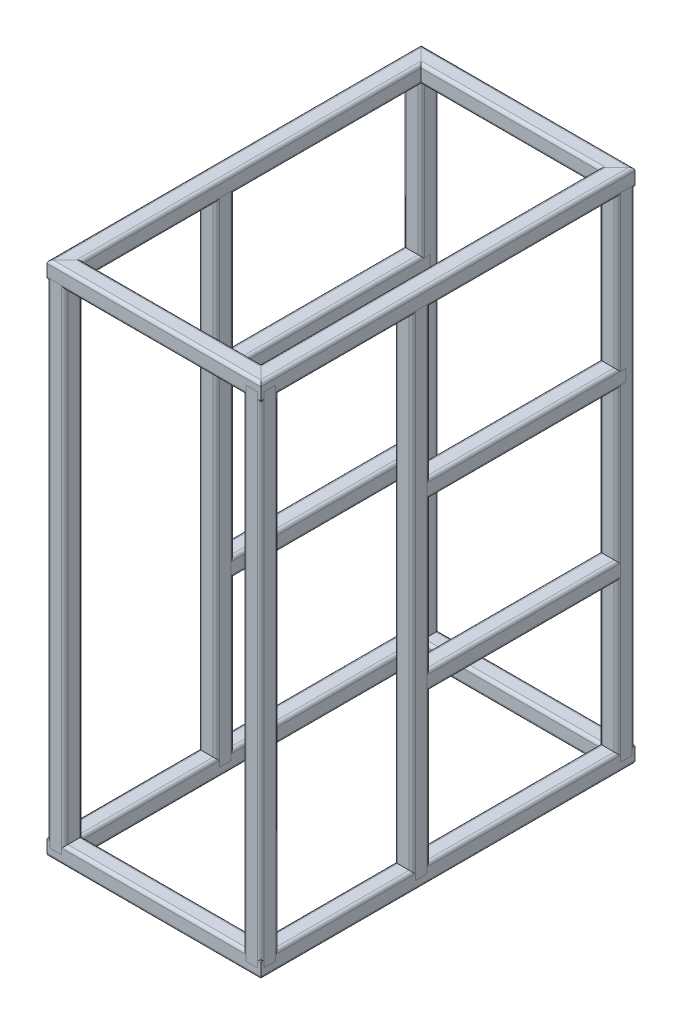
from build123d import *

# Parameters (mm, degrees)
F_30_X_30_X_2_6_1_DEPTH      = 352.213203436
F_30_X_30_X_2_6_1_DEPTH_BACK = 22.213203436
F_30_X_30_X_2_6_1_2_DEPTH    = 644.426406871
F_30_X_30_X_2_6_1_3_DEPTH    = 374.426406871
F_30_X_30_X_2_6_1_4_DEPTH    = 644.426406871
F_30_X_30_X_2_6_2_DEPTH      = 840
F_30_X_30_X_2_6_2_2_DEPTH    = 840
F_30_X_30_X_2_6_2_3_DEPTH    = 840
F_30_X_30_X_2_6_2_4_DEPTH    = 840
F_30_X_30_X_2_6_4_DEPTH      = 352.213203436
F_30_X_30_X_2_6_4_DEPTH_BACK = 22.213203436
F_30_X_30_X_2_6_4_2_DEPTH    = 644.426406871
F_30_X_30_X_2_6_4_3_DEPTH    = 374.426406871
F_30_X_30_X_2_6_4_4_DEPTH    = 644.426406871
F_30_X_30_X_2_6_5_DEPTH      = 840
F_30_X_30_X_2_6_5_2_DEPTH    = 840
F_30_X_30_X_2_6_6_DEPTH      = 345
F_30_X_30_X_2_6_6_2_DEPTH    = 345
F_30_X_30_X_2_6_6_3_DEPTH    = 345
F_30_X_30_X_2_6_6_4_DEPTH    = 345


with BuildPart() as part:
    # Sketch1 → 方形管 30 X 30 X 2.6(1) (new, two sides)
    with BuildSketch(Plane(origin=(-165, -420, 0), x_dir=(0, 1, 0), z_dir=(1, 0, 0))) as f_30_x_30_x_2_6_1_sk:
        with BuildLine():
            Line((-9.8, -15), (9.8, -15))
            ThreePointArc((9.8, -15), (13.476955262, -13.476955262), (15, -9.8))
            Line((15, -9.8), (15, 9.8))
            ThreePointArc((15, 9.8), (13.476955262, 13.476955262), (9.8, 15))
            Line((9.8, 15), (-9.8, 15))
            ThreePointArc((-9.8, 15), (-13.476955262, 13.476955262), (-15, 9.8))
            Line((-15, 9.8), (-15, -9.8))
            ThreePointArc((-15, -9.8), (-13.476955262, -13.476955262), (-9.8, -15))
        make_face()
        with BuildLine():
            Line((-9.8, -12.4), (9.8, -12.4))
            ThreePointArc((9.8, -12.4), (11.638477631, -11.638477631), (12.4, -9.8))
            Line((12.4, -9.8), (12.4, 9.8))
            ThreePointArc((12.4, 9.8), (11.638477631, 11.638477631), (9.8, 12.4))
            Line((9.8, 12.4), (-9.8, 12.4))
            ThreePointArc((-9.8, 12.4), (-11.638477631, 11.638477631), (-12.4, 9.8))
            Line((-12.4, 9.8), (-12.4, -9.8))
            ThreePointArc((-12.4, -9.8), (-11.638477631, -11.638477631), (-9.8, -12.4))
        make_face(mode=Mode.SUBTRACT)
    extrude(amount=F_30_X_30_X_2_6_1_DEPTH)
    extrude(f_30_x_30_x_2_6_1_sk.sketch, amount=-F_30_X_30_X_2_6_1_DEPTH_BACK)

    # 方形管 30 X 30 X 2.6(1) mitre 1
    split(bisect_by=Plane(origin=(-165, -420, 0), x_dir=(0, 1, 0), z_dir=(0.707106781, 0, 0.707106781)), keep=Keep.TOP)

    # 方形管 30 X 30 X 2.6(1) mitre 2
    split(bisect_by=Plane(origin=(165, -420, 0), x_dir=(0, -1, 0), z_dir=(-0.707106781, 0, 0.707106781)), keep=Keep.TOP)


with BuildPart() as body_2:
    # Sketch1 on segment 2 (carried to segment 2) → 30 X 30 X 2.6_1 2 (new body)
    with BuildSketch(Plane(origin=(165, -420, 22.213203436), x_dir=(0, 1, 0), z_dir=(0, 0, -1))):
        with BuildLine():
            Line((-9.8, -15), (9.8, -15))
            ThreePointArc((9.8, -15), (13.476955262, -13.476955262), (15, -9.8))
            Line((15, -9.8), (15, 9.8))
            ThreePointArc((15, 9.8), (13.476955262, 13.476955262), (9.8, 15))
            Line((9.8, 15), (-9.8, 15))
            ThreePointArc((-9.8, 15), (-13.476955262, 13.476955262), (-15, 9.8))
            Line((-15, 9.8), (-15, -9.8))
            ThreePointArc((-15, -9.8), (-13.476955262, -13.476955262), (-9.8, -15))
        make_face()
        with BuildLine():
            Line((-9.8, -12.4), (9.8, -12.4))
            ThreePointArc((9.8, -12.4), (11.638477631, -11.638477631), (12.4, -9.8))
            Line((12.4, -9.8), (12.4, 9.8))
            ThreePointArc((12.4, 9.8), (11.638477631, 11.638477631), (9.8, 12.4))
            Line((9.8, 12.4), (-9.8, 12.4))
            ThreePointArc((-9.8, 12.4), (-11.638477631, 11.638477631), (-12.4, 9.8))
            Line((-12.4, 9.8), (-12.4, -9.8))
            ThreePointArc((-12.4, -9.8), (-11.638477631, -11.638477631), (-9.8, -12.4))
        make_face(mode=Mode.SUBTRACT)
    extrude(amount=F_30_X_30_X_2_6_1_2_DEPTH)

    # 30 X 30 X 2.6_1 2 mitre 1
    split(bisect_by=Plane(origin=(165, -420, 0), x_dir=(0, 1, 0), z_dir=(0.707106781, 0, -0.707106781)), keep=Keep.TOP)

    # 30 X 30 X 2.6_1 2 mitre 2
    split(bisect_by=Plane(origin=(165, -420, -600), x_dir=(0, 1, 0), z_dir=(0.707106781, 0, 0.707106781)), keep=Keep.TOP)


with BuildPart() as body_3:
    # Sketch1 on segment 3 (carried to segment 3) → 30 X 30 X 2.6_1 3 (new body)
    with BuildSketch(Plane(origin=(187.213203436, -420, -600), x_dir=(0, 1, 0), z_dir=(-1, 0, 0))):
        with BuildLine():
            Line((-9.8, -15), (9.8, -15))
            ThreePointArc((9.8, -15), (13.476955262, -13.476955262), (15, -9.8))
            Line((15, -9.8), (15, 9.8))
            ThreePointArc((15, 9.8), (13.476955262, 13.476955262), (9.8, 15))
            Line((9.8, 15), (-9.8, 15))
            ThreePointArc((-9.8, 15), (-13.476955262, 13.476955262), (-15, 9.8))
            Line((-15, 9.8), (-15, -9.8))
            ThreePointArc((-15, -9.8), (-13.476955262, -13.476955262), (-9.8, -15))
        make_face()
        with BuildLine():
            Line((-9.8, -12.4), (9.8, -12.4))
            ThreePointArc((9.8, -12.4), (11.638477631, -11.638477631), (12.4, -9.8))
            Line((12.4, -9.8), (12.4, 9.8))
            ThreePointArc((12.4, 9.8), (11.638477631, 11.638477631), (9.8, 12.4))
            Line((9.8, 12.4), (-9.8, 12.4))
            ThreePointArc((-9.8, 12.4), (-11.638477631, 11.638477631), (-12.4, 9.8))
            Line((-12.4, 9.8), (-12.4, -9.8))
            ThreePointArc((-12.4, -9.8), (-11.638477631, -11.638477631), (-9.8, -12.4))
        make_face(mode=Mode.SUBTRACT)
    extrude(amount=F_30_X_30_X_2_6_1_3_DEPTH)

    # 30 X 30 X 2.6_1 3 mitre 1
    split(bisect_by=Plane(origin=(165, -420, -600), x_dir=(0, -1, 0), z_dir=(-0.707106781, 0, -0.707106781)), keep=Keep.TOP)

    # 30 X 30 X 2.6_1 3 mitre 2
    split(bisect_by=Plane(origin=(-165, -420, -600), x_dir=(0, 1, 0), z_dir=(0.707106781, 0, -0.707106781)), keep=Keep.TOP)


with BuildPart() as body_4:
    # Sketch1 on segment 4 (carried to segment 4) → 30 X 30 X 2.6_1 4 (new body)
    with BuildSketch(Plane(origin=(-165, -420, -622.213203436), x_dir=(0, 1, 0), z_dir=(0, 0, 1))):
        with BuildLine():
            Line((-9.8, -15), (9.8, -15))
            ThreePointArc((9.8, -15), (13.476955262, -13.476955262), (15, -9.8))
            Line((15, -9.8), (15, 9.8))
            ThreePointArc((15, 9.8), (13.476955262, 13.476955262), (9.8, 15))
            Line((9.8, 15), (-9.8, 15))
            ThreePointArc((-9.8, 15), (-13.476955262, 13.476955262), (-15, 9.8))
            Line((-15, 9.8), (-15, -9.8))
            ThreePointArc((-15, -9.8), (-13.476955262, -13.476955262), (-9.8, -15))
        make_face()
        with BuildLine():
            Line((-9.8, -12.4), (9.8, -12.4))
            ThreePointArc((9.8, -12.4), (11.638477631, -11.638477631), (12.4, -9.8))
            Line((12.4, -9.8), (12.4, 9.8))
            ThreePointArc((12.4, 9.8), (11.638477631, 11.638477631), (9.8, 12.4))
            Line((9.8, 12.4), (-9.8, 12.4))
            ThreePointArc((-9.8, 12.4), (-11.638477631, 11.638477631), (-12.4, 9.8))
            Line((-12.4, 9.8), (-12.4, -9.8))
            ThreePointArc((-12.4, -9.8), (-11.638477631, -11.638477631), (-9.8, -12.4))
        make_face(mode=Mode.SUBTRACT)
    extrude(amount=F_30_X_30_X_2_6_1_4_DEPTH)

    # 30 X 30 X 2.6_1 4 mitre 1
    split(bisect_by=Plane(origin=(-165, -420, 0), x_dir=(0, -1, 0), z_dir=(-0.707106781, 0, -0.707106781)), keep=Keep.TOP)

    # 30 X 30 X 2.6_1 4 mitre 2
    split(bisect_by=Plane(origin=(-165, -420, -600), x_dir=(0, -1, 0), z_dir=(-0.707106781, 0, 0.707106781)), keep=Keep.TOP)


with BuildPart() as body_5:
    # Sketch11 → 方形管 30 X 30 X 2.6(2) (new body)
    with BuildSketch(Plane(origin=(165, -420, 0), x_dir=(-1, 0, 0), z_dir=(0, 1, 0))):
        with BuildLine():
            Line((-9.8, -15), (9.8, -15))
            ThreePointArc((9.8, -15), (13.476955262, -13.476955262), (15, -9.8))
            Line((15, -9.8), (15, 9.8))
            ThreePointArc((15, 9.8), (13.476955262, 13.476955262), (9.8, 15))
            Line((9.8, 15), (-9.8, 15))
            ThreePointArc((-9.8, 15), (-13.476955262, 13.476955262), (-15, 9.8))
            Line((-15, 9.8), (-15, -9.8))
            ThreePointArc((-15, -9.8), (-13.476955262, -13.476955262), (-9.8, -15))
        make_face()
        with BuildLine():
            Line((-9.8, -12.4), (9.8, -12.4))
            ThreePointArc((9.8, -12.4), (11.638477631, -11.638477631), (12.4, -9.8))
            Line((12.4, -9.8), (12.4, 9.8))
            ThreePointArc((12.4, 9.8), (11.638477631, 11.638477631), (9.8, 12.4))
            Line((9.8, 12.4), (-9.8, 12.4))
            ThreePointArc((-9.8, 12.4), (-11.638477631, 11.638477631), (-12.4, 9.8))
            Line((-12.4, 9.8), (-12.4, -9.8))
            ThreePointArc((-12.4, -9.8), (-11.638477631, -11.638477631), (-9.8, -12.4))
        make_face(mode=Mode.SUBTRACT)
    extrude(amount=F_30_X_30_X_2_6_2_DEPTH)


with BuildPart() as body_6:
    # Sketch11 on segment 2 (carried to segment 2) → 30 X 30 X 2.6_2 2 (new body)
    with BuildSketch(Plane(origin=(-165, -420, 0), x_dir=(-1, 0, 0), z_dir=(0, 1, 0))):
        with BuildLine():
            Line((-9.8, -15), (9.8, -15))
            ThreePointArc((9.8, -15), (13.476955262, -13.476955262), (15, -9.8))
            Line((15, -9.8), (15, 9.8))
            ThreePointArc((15, 9.8), (13.476955262, 13.476955262), (9.8, 15))
            Line((9.8, 15), (-9.8, 15))
            ThreePointArc((-9.8, 15), (-13.476955262, 13.476955262), (-15, 9.8))
            Line((-15, 9.8), (-15, -9.8))
            ThreePointArc((-15, -9.8), (-13.476955262, -13.476955262), (-9.8, -15))
        make_face()
        with BuildLine():
            Line((-9.8, -12.4), (9.8, -12.4))
            ThreePointArc((9.8, -12.4), (11.638477631, -11.638477631), (12.4, -9.8))
            Line((12.4, -9.8), (12.4, 9.8))
            ThreePointArc((12.4, 9.8), (11.638477631, 11.638477631), (9.8, 12.4))
            Line((9.8, 12.4), (-9.8, 12.4))
            ThreePointArc((-9.8, 12.4), (-11.638477631, 11.638477631), (-12.4, 9.8))
            Line((-12.4, 9.8), (-12.4, -9.8))
            ThreePointArc((-12.4, -9.8), (-11.638477631, -11.638477631), (-9.8, -12.4))
        make_face(mode=Mode.SUBTRACT)
    extrude(amount=F_30_X_30_X_2_6_2_2_DEPTH)


with BuildPart() as body_7:
    # Sketch11 on segment 3 (carried to segment 3) → 30 X 30 X 2.6_2 3 (new body)
    with BuildSketch(Plane(origin=(165, -420, -600), x_dir=(-1, 0, 0), z_dir=(0, 1, 0))):
        with BuildLine():
            Line((-9.8, -15), (9.8, -15))
            ThreePointArc((9.8, -15), (13.476955262, -13.476955262), (15, -9.8))
            Line((15, -9.8), (15, 9.8))
            ThreePointArc((15, 9.8), (13.476955262, 13.476955262), (9.8, 15))
            Line((9.8, 15), (-9.8, 15))
            ThreePointArc((-9.8, 15), (-13.476955262, 13.476955262), (-15, 9.8))
            Line((-15, 9.8), (-15, -9.8))
            ThreePointArc((-15, -9.8), (-13.476955262, -13.476955262), (-9.8, -15))
        make_face()
        with BuildLine():
            Line((-9.8, -12.4), (9.8, -12.4))
            ThreePointArc((9.8, -12.4), (11.638477631, -11.638477631), (12.4, -9.8))
            Line((12.4, -9.8), (12.4, 9.8))
            ThreePointArc((12.4, 9.8), (11.638477631, 11.638477631), (9.8, 12.4))
            Line((9.8, 12.4), (-9.8, 12.4))
            ThreePointArc((-9.8, 12.4), (-11.638477631, 11.638477631), (-12.4, 9.8))
            Line((-12.4, 9.8), (-12.4, -9.8))
            ThreePointArc((-12.4, -9.8), (-11.638477631, -11.638477631), (-9.8, -12.4))
        make_face(mode=Mode.SUBTRACT)
    extrude(amount=F_30_X_30_X_2_6_2_3_DEPTH)


with BuildPart() as body_8:
    # Sketch11 on segment 4 (carried to segment 4) → 30 X 30 X 2.6_2 4 (new body)
    with BuildSketch(Plane(origin=(-165, -420, -600), x_dir=(-1, 0, 0), z_dir=(0, 1, 0))):
        with BuildLine():
            Line((-9.8, -15), (9.8, -15))
            ThreePointArc((9.8, -15), (13.476955262, -13.476955262), (15, -9.8))
            Line((15, -9.8), (15, 9.8))
            ThreePointArc((15, 9.8), (13.476955262, 13.476955262), (9.8, 15))
            Line((9.8, 15), (-9.8, 15))
            ThreePointArc((-9.8, 15), (-13.476955262, 13.476955262), (-15, 9.8))
            Line((-15, 9.8), (-15, -9.8))
            ThreePointArc((-15, -9.8), (-13.476955262, -13.476955262), (-9.8, -15))
        make_face()
        with BuildLine():
            Line((-9.8, -12.4), (9.8, -12.4))
            ThreePointArc((9.8, -12.4), (11.638477631, -11.638477631), (12.4, -9.8))
            Line((12.4, -9.8), (12.4, 9.8))
            ThreePointArc((12.4, 9.8), (11.638477631, 11.638477631), (9.8, 12.4))
            Line((9.8, 12.4), (-9.8, 12.4))
            ThreePointArc((-9.8, 12.4), (-11.638477631, 11.638477631), (-12.4, 9.8))
            Line((-12.4, 9.8), (-12.4, -9.8))
            ThreePointArc((-12.4, -9.8), (-11.638477631, -11.638477631), (-9.8, -12.4))
        make_face(mode=Mode.SUBTRACT)
    extrude(amount=F_30_X_30_X_2_6_2_4_DEPTH)


with BuildPart() as body_9:
    # Sketch12 → 方形管 30 X 30 X 2.6(4) (new, two sides)
    with BuildSketch(Plane(origin=(-165, 420, 0), x_dir=(0, 1, 0), z_dir=(1, 0, 0))) as f_30_x_30_x_2_6_4_sk:
        with BuildLine():
            Line((-9.8, -15), (9.8, -15))
            ThreePointArc((9.8, -15), (13.476955262, -13.476955262), (15, -9.8))
            Line((15, -9.8), (15, 9.8))
            ThreePointArc((15, 9.8), (13.476955262, 13.476955262), (9.8, 15))
            Line((9.8, 15), (-9.8, 15))
            ThreePointArc((-9.8, 15), (-13.476955262, 13.476955262), (-15, 9.8))
            Line((-15, 9.8), (-15, -9.8))
            ThreePointArc((-15, -9.8), (-13.476955262, -13.476955262), (-9.8, -15))
        make_face()
        with BuildLine():
            Line((-9.8, -12.4), (9.8, -12.4))
            ThreePointArc((9.8, -12.4), (11.638477631, -11.638477631), (12.4, -9.8))
            Line((12.4, -9.8), (12.4, 9.8))
            ThreePointArc((12.4, 9.8), (11.638477631, 11.638477631), (9.8, 12.4))
            Line((9.8, 12.4), (-9.8, 12.4))
            ThreePointArc((-9.8, 12.4), (-11.638477631, 11.638477631), (-12.4, 9.8))
            Line((-12.4, 9.8), (-12.4, -9.8))
            ThreePointArc((-12.4, -9.8), (-11.638477631, -11.638477631), (-9.8, -12.4))
        make_face(mode=Mode.SUBTRACT)
    extrude(amount=F_30_X_30_X_2_6_4_DEPTH)
    extrude(f_30_x_30_x_2_6_4_sk.sketch, amount=-F_30_X_30_X_2_6_4_DEPTH_BACK)

    # 方形管 30 X 30 X 2.6(4) mitre 1
    split(bisect_by=Plane(origin=(-165, 420, 0), x_dir=(0, 1, 0), z_dir=(0.707106781, 0, 0.707106781)), keep=Keep.TOP)

    # 方形管 30 X 30 X 2.6(4) mitre 2
    split(bisect_by=Plane(origin=(165, 420, 0), x_dir=(0, -1, 0), z_dir=(-0.707106781, 0, 0.707106781)), keep=Keep.TOP)


with BuildPart() as body_10:
    # Sketch12 on segment 2 (carried to segment 2) → 30 X 30 X 2.6_4 2 (new body)
    with BuildSketch(Plane(origin=(165, 420, 22.213203436), x_dir=(0, 1, 0), z_dir=(0, 0, -1))):
        with BuildLine():
            Line((-9.8, -15), (9.8, -15))
            ThreePointArc((9.8, -15), (13.476955262, -13.476955262), (15, -9.8))
            Line((15, -9.8), (15, 9.8))
            ThreePointArc((15, 9.8), (13.476955262, 13.476955262), (9.8, 15))
            Line((9.8, 15), (-9.8, 15))
            ThreePointArc((-9.8, 15), (-13.476955262, 13.476955262), (-15, 9.8))
            Line((-15, 9.8), (-15, -9.8))
            ThreePointArc((-15, -9.8), (-13.476955262, -13.476955262), (-9.8, -15))
        make_face()
        with BuildLine():
            Line((-9.8, -12.4), (9.8, -12.4))
            ThreePointArc((9.8, -12.4), (11.638477631, -11.638477631), (12.4, -9.8))
            Line((12.4, -9.8), (12.4, 9.8))
            ThreePointArc((12.4, 9.8), (11.638477631, 11.638477631), (9.8, 12.4))
            Line((9.8, 12.4), (-9.8, 12.4))
            ThreePointArc((-9.8, 12.4), (-11.638477631, 11.638477631), (-12.4, 9.8))
            Line((-12.4, 9.8), (-12.4, -9.8))
            ThreePointArc((-12.4, -9.8), (-11.638477631, -11.638477631), (-9.8, -12.4))
        make_face(mode=Mode.SUBTRACT)
    extrude(amount=F_30_X_30_X_2_6_4_2_DEPTH)

    # 30 X 30 X 2.6_4 2 mitre 1
    split(bisect_by=Plane(origin=(165, 420, 0), x_dir=(0, 1, 0), z_dir=(0.707106781, 0, -0.707106781)), keep=Keep.TOP)

    # 30 X 30 X 2.6_4 2 mitre 2
    split(bisect_by=Plane(origin=(165, 420, -600), x_dir=(0, 1, 0), z_dir=(0.707106781, 0, 0.707106781)), keep=Keep.TOP)


with BuildPart() as body_11:
    # Sketch12 on segment 3 (carried to segment 3) → 30 X 30 X 2.6_4 3 (new body)
    with BuildSketch(Plane(origin=(187.213203436, 420, -600), x_dir=(0, 1, 0), z_dir=(-1, 0, 0))):
        with BuildLine():
            Line((-9.8, -15), (9.8, -15))
            ThreePointArc((9.8, -15), (13.476955262, -13.476955262), (15, -9.8))
            Line((15, -9.8), (15, 9.8))
            ThreePointArc((15, 9.8), (13.476955262, 13.476955262), (9.8, 15))
            Line((9.8, 15), (-9.8, 15))
            ThreePointArc((-9.8, 15), (-13.476955262, 13.476955262), (-15, 9.8))
            Line((-15, 9.8), (-15, -9.8))
            ThreePointArc((-15, -9.8), (-13.476955262, -13.476955262), (-9.8, -15))
        make_face()
        with BuildLine():
            Line((-9.8, -12.4), (9.8, -12.4))
            ThreePointArc((9.8, -12.4), (11.638477631, -11.638477631), (12.4, -9.8))
            Line((12.4, -9.8), (12.4, 9.8))
            ThreePointArc((12.4, 9.8), (11.638477631, 11.638477631), (9.8, 12.4))
            Line((9.8, 12.4), (-9.8, 12.4))
            ThreePointArc((-9.8, 12.4), (-11.638477631, 11.638477631), (-12.4, 9.8))
            Line((-12.4, 9.8), (-12.4, -9.8))
            ThreePointArc((-12.4, -9.8), (-11.638477631, -11.638477631), (-9.8, -12.4))
        make_face(mode=Mode.SUBTRACT)
    extrude(amount=F_30_X_30_X_2_6_4_3_DEPTH)

    # 30 X 30 X 2.6_4 3 mitre 1
    split(bisect_by=Plane(origin=(-165, 420, -600), x_dir=(0, 1, 0), z_dir=(0.707106781, 0, -0.707106781)), keep=Keep.TOP)

    # 30 X 30 X 2.6_4 3 mitre 2
    split(bisect_by=Plane(origin=(165, 420, -600), x_dir=(0, -1, 0), z_dir=(-0.707106781, 0, -0.707106781)), keep=Keep.TOP)


with BuildPart() as body_12:
    # Sketch12 on segment 4 (carried to segment 4) → 30 X 30 X 2.6_4 4 (new body)
    with BuildSketch(Plane(origin=(-165, 420, -622.213203436), x_dir=(0, 1, 0), z_dir=(0, 0, 1))):
        with BuildLine():
            Line((-9.8, -15), (9.8, -15))
            ThreePointArc((9.8, -15), (13.476955262, -13.476955262), (15, -9.8))
            Line((15, -9.8), (15, 9.8))
            ThreePointArc((15, 9.8), (13.476955262, 13.476955262), (9.8, 15))
            Line((9.8, 15), (-9.8, 15))
            ThreePointArc((-9.8, 15), (-13.476955262, 13.476955262), (-15, 9.8))
            Line((-15, 9.8), (-15, -9.8))
            ThreePointArc((-15, -9.8), (-13.476955262, -13.476955262), (-9.8, -15))
        make_face()
        with BuildLine():
            Line((-9.8, -12.4), (9.8, -12.4))
            ThreePointArc((9.8, -12.4), (11.638477631, -11.638477631), (12.4, -9.8))
            Line((12.4, -9.8), (12.4, 9.8))
            ThreePointArc((12.4, 9.8), (11.638477631, 11.638477631), (9.8, 12.4))
            Line((9.8, 12.4), (-9.8, 12.4))
            ThreePointArc((-9.8, 12.4), (-11.638477631, 11.638477631), (-12.4, 9.8))
            Line((-12.4, 9.8), (-12.4, -9.8))
            ThreePointArc((-12.4, -9.8), (-11.638477631, -11.638477631), (-9.8, -12.4))
        make_face(mode=Mode.SUBTRACT)
    extrude(amount=F_30_X_30_X_2_6_4_4_DEPTH)

    # 30 X 30 X 2.6_4 4 mitre 1
    split(bisect_by=Plane(origin=(-165, 420, 0), x_dir=(0, -1, 0), z_dir=(-0.707106781, 0, -0.707106781)), keep=Keep.TOP)

    # 30 X 30 X 2.6_4 4 mitre 2
    split(bisect_by=Plane(origin=(-165, 420, -600), x_dir=(0, -1, 0), z_dir=(-0.707106781, 0, 0.707106781)), keep=Keep.TOP)


with BuildPart() as body_13:
    # Sketch13 → 方形管 30 X 30 X 2.6(5) (new body)
    with BuildSketch(Plane(origin=(165, -420, -255), x_dir=(1, 0, 0), z_dir=(0, 1, 0))):
        with BuildLine():
            Line((-9.8, -15), (9.8, -15))
            ThreePointArc((9.8, -15), (13.476955262, -13.476955262), (15, -9.8))
            Line((15, -9.8), (15, 9.8))
            ThreePointArc((15, 9.8), (13.476955262, 13.476955262), (9.8, 15))
            Line((9.8, 15), (-9.8, 15))
            ThreePointArc((-9.8, 15), (-13.476955262, 13.476955262), (-15, 9.8))
            Line((-15, 9.8), (-15, -9.8))
            ThreePointArc((-15, -9.8), (-13.476955262, -13.476955262), (-9.8, -15))
        make_face()
        with BuildLine():
            Line((-9.8, -12.4), (9.8, -12.4))
            ThreePointArc((9.8, -12.4), (11.638477631, -11.638477631), (12.4, -9.8))
            Line((12.4, -9.8), (12.4, 9.8))
            ThreePointArc((12.4, 9.8), (11.638477631, 11.638477631), (9.8, 12.4))
            Line((9.8, 12.4), (-9.8, 12.4))
            ThreePointArc((-9.8, 12.4), (-11.638477631, 11.638477631), (-12.4, 9.8))
            Line((-12.4, 9.8), (-12.4, -9.8))
            ThreePointArc((-12.4, -9.8), (-11.638477631, -11.638477631), (-9.8, -12.4))
        make_face(mode=Mode.SUBTRACT)
    extrude(amount=F_30_X_30_X_2_6_5_DEPTH)


with BuildPart() as body_14:
    # Sketch13 on segment 2 (carried to segment 2) → 30 X 30 X 2.6_5 2 (new body)
    with BuildSketch(Plane(origin=(-165, -420, -255), x_dir=(1, 0, 0), z_dir=(0, 1, 0))):
        with BuildLine():
            Line((-9.8, -15), (9.8, -15))
            ThreePointArc((9.8, -15), (13.476955262, -13.476955262), (15, -9.8))
            Line((15, -9.8), (15, 9.8))
            ThreePointArc((15, 9.8), (13.476955262, 13.476955262), (9.8, 15))
            Line((9.8, 15), (-9.8, 15))
            ThreePointArc((-9.8, 15), (-13.476955262, 13.476955262), (-15, 9.8))
            Line((-15, 9.8), (-15, -9.8))
            ThreePointArc((-15, -9.8), (-13.476955262, -13.476955262), (-9.8, -15))
        make_face()
        with BuildLine():
            Line((-9.8, -12.4), (9.8, -12.4))
            ThreePointArc((9.8, -12.4), (11.638477631, -11.638477631), (12.4, -9.8))
            Line((12.4, -9.8), (12.4, 9.8))
            ThreePointArc((12.4, 9.8), (11.638477631, 11.638477631), (9.8, 12.4))
            Line((9.8, 12.4), (-9.8, 12.4))
            ThreePointArc((-9.8, 12.4), (-11.638477631, 11.638477631), (-12.4, 9.8))
            Line((-12.4, 9.8), (-12.4, -9.8))
            ThreePointArc((-12.4, -9.8), (-11.638477631, -11.638477631), (-9.8, -12.4))
        make_face(mode=Mode.SUBTRACT)
    extrude(amount=F_30_X_30_X_2_6_5_2_DEPTH)


with BuildPart() as body_15:
    # Sketch14 → 方形管 30 X 30 X 2.6(6) (new body)
    with BuildSketch(Plane(origin=(165, -140, -255), x_dir=(1, 0, 0), z_dir=(0, 0, -1))):
        with BuildLine():
            Line((-9.8, -15), (9.8, -15))
            ThreePointArc((9.8, -15), (13.476955262, -13.476955262), (15, -9.8))
            Line((15, -9.8), (15, 9.8))
            ThreePointArc((15, 9.8), (13.476955262, 13.476955262), (9.8, 15))
            Line((9.8, 15), (-9.8, 15))
            ThreePointArc((-9.8, 15), (-13.476955262, 13.476955262), (-15, 9.8))
            Line((-15, 9.8), (-15, -9.8))
            ThreePointArc((-15, -9.8), (-13.476955262, -13.476955262), (-9.8, -15))
        make_face()
        with BuildLine():
            Line((-9.8, -12.4), (9.8, -12.4))
            ThreePointArc((9.8, -12.4), (11.638477631, -11.638477631), (12.4, -9.8))
            Line((12.4, -9.8), (12.4, 9.8))
            ThreePointArc((12.4, 9.8), (11.638477631, 11.638477631), (9.8, 12.4))
            Line((9.8, 12.4), (-9.8, 12.4))
            ThreePointArc((-9.8, 12.4), (-11.638477631, 11.638477631), (-12.4, 9.8))
            Line((-12.4, 9.8), (-12.4, -9.8))
            ThreePointArc((-12.4, -9.8), (-11.638477631, -11.638477631), (-9.8, -12.4))
        make_face(mode=Mode.SUBTRACT)
    extrude(amount=F_30_X_30_X_2_6_6_DEPTH)


with BuildPart() as body_16:
    # Sketch14 on segment 2 (carried to segment 2) → 30 X 30 X 2.6_6 2 (new body)
    with BuildSketch(Plane(origin=(165, 140, -255), x_dir=(1, 0, 0), z_dir=(0, 0, -1))):
        with BuildLine():
            Line((-9.8, -15), (9.8, -15))
            ThreePointArc((9.8, -15), (13.476955262, -13.476955262), (15, -9.8))
            Line((15, -9.8), (15, 9.8))
            ThreePointArc((15, 9.8), (13.476955262, 13.476955262), (9.8, 15))
            Line((9.8, 15), (-9.8, 15))
            ThreePointArc((-9.8, 15), (-13.476955262, 13.476955262), (-15, 9.8))
            Line((-15, 9.8), (-15, -9.8))
            ThreePointArc((-15, -9.8), (-13.476955262, -13.476955262), (-9.8, -15))
        make_face()
        with BuildLine():
            Line((-9.8, -12.4), (9.8, -12.4))
            ThreePointArc((9.8, -12.4), (11.638477631, -11.638477631), (12.4, -9.8))
            Line((12.4, -9.8), (12.4, 9.8))
            ThreePointArc((12.4, 9.8), (11.638477631, 11.638477631), (9.8, 12.4))
            Line((9.8, 12.4), (-9.8, 12.4))
            ThreePointArc((-9.8, 12.4), (-11.638477631, 11.638477631), (-12.4, 9.8))
            Line((-12.4, 9.8), (-12.4, -9.8))
            ThreePointArc((-12.4, -9.8), (-11.638477631, -11.638477631), (-9.8, -12.4))
        make_face(mode=Mode.SUBTRACT)
    extrude(amount=F_30_X_30_X_2_6_6_2_DEPTH)


with BuildPart() as body_17:
    # Sketch14 on segment 3 (carried to segment 3) → 30 X 30 X 2.6_6 3 (new body)
    with BuildSketch(Plane(origin=(-165, -140, -255), x_dir=(1, 0, 0), z_dir=(0, 0, -1))):
        with BuildLine():
            Line((-9.8, -15), (9.8, -15))
            ThreePointArc((9.8, -15), (13.476955262, -13.476955262), (15, -9.8))
            Line((15, -9.8), (15, 9.8))
            ThreePointArc((15, 9.8), (13.476955262, 13.476955262), (9.8, 15))
            Line((9.8, 15), (-9.8, 15))
            ThreePointArc((-9.8, 15), (-13.476955262, 13.476955262), (-15, 9.8))
            Line((-15, 9.8), (-15, -9.8))
            ThreePointArc((-15, -9.8), (-13.476955262, -13.476955262), (-9.8, -15))
        make_face()
        with BuildLine():
            Line((-9.8, -12.4), (9.8, -12.4))
            ThreePointArc((9.8, -12.4), (11.638477631, -11.638477631), (12.4, -9.8))
            Line((12.4, -9.8), (12.4, 9.8))
            ThreePointArc((12.4, 9.8), (11.638477631, 11.638477631), (9.8, 12.4))
            Line((9.8, 12.4), (-9.8, 12.4))
            ThreePointArc((-9.8, 12.4), (-11.638477631, 11.638477631), (-12.4, 9.8))
            Line((-12.4, 9.8), (-12.4, -9.8))
            ThreePointArc((-12.4, -9.8), (-11.638477631, -11.638477631), (-9.8, -12.4))
        make_face(mode=Mode.SUBTRACT)
    extrude(amount=F_30_X_30_X_2_6_6_3_DEPTH)


with BuildPart() as body_18:
    # Sketch14 on segment 4 (carried to segment 4) → 30 X 30 X 2.6_6 4 (new body)
    with BuildSketch(Plane(origin=(-165, 140, -255), x_dir=(1, 0, 0), z_dir=(0, 0, -1))):
        with BuildLine():
            Line((-9.8, -15), (9.8, -15))
            ThreePointArc((9.8, -15), (13.476955262, -13.476955262), (15, -9.8))
            Line((15, -9.8), (15, 9.8))
            ThreePointArc((15, 9.8), (13.476955262, 13.476955262), (9.8, 15))
            Line((9.8, 15), (-9.8, 15))
            ThreePointArc((-9.8, 15), (-13.476955262, 13.476955262), (-15, 9.8))
            Line((-15, 9.8), (-15, -9.8))
            ThreePointArc((-15, -9.8), (-13.476955262, -13.476955262), (-9.8, -15))
        make_face()
        with BuildLine():
            Line((-9.8, -12.4), (9.8, -12.4))
            ThreePointArc((9.8, -12.4), (11.638477631, -11.638477631), (12.4, -9.8))
            Line((12.4, -9.8), (12.4, 9.8))
            ThreePointArc((12.4, 9.8), (11.638477631, 11.638477631), (9.8, 12.4))
            Line((9.8, 12.4), (-9.8, 12.4))
            ThreePointArc((-9.8, 12.4), (-11.638477631, 11.638477631), (-12.4, 9.8))
            Line((-12.4, 9.8), (-12.4, -9.8))
            ThreePointArc((-12.4, -9.8), (-11.638477631, -11.638477631), (-9.8, -12.4))
        make_face(mode=Mode.SUBTRACT)
    extrude(amount=F_30_X_30_X_2_6_6_4_DEPTH)


solid = Compound([part.part, body_2.part, body_3.part, body_4.part, body_5.part, body_6.part, body_7.part, body_8.part, body_9.part, body_10.part, body_11.part, body_12.part, body_13.part, body_14.part, body_15.part, body_16.part, body_17.part, body_18.part])
